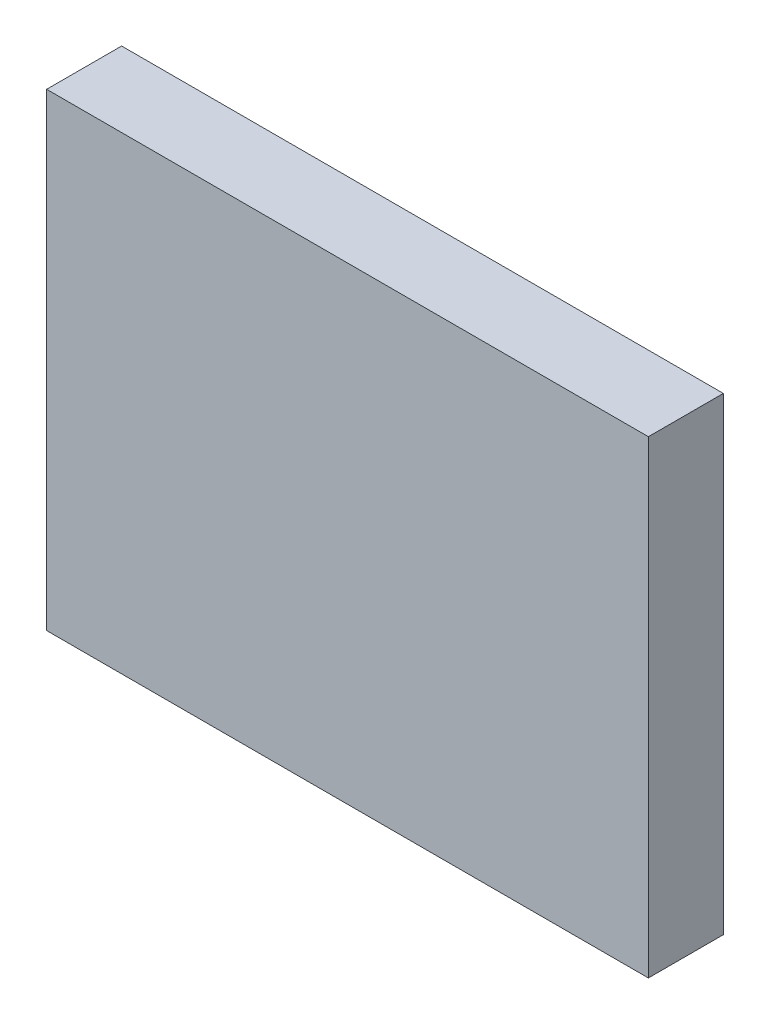
from build123d import *

# Parameters (mm, degrees)
SKETCH1_W               = 8.027
SKETCH1_H               = 6.2535
COMPONENT_OUTLINE_DEPTH = 1


with BuildPart() as part:
    # Sketch1 → Component_Outline (new body)
    with BuildSketch(Plane.XY):
        with Locations((0, -0.68325)):
            Rectangle(SKETCH1_W, SKETCH1_H)
    extrude(amount=COMPONENT_OUTLINE_DEPTH)


solid = part.part
